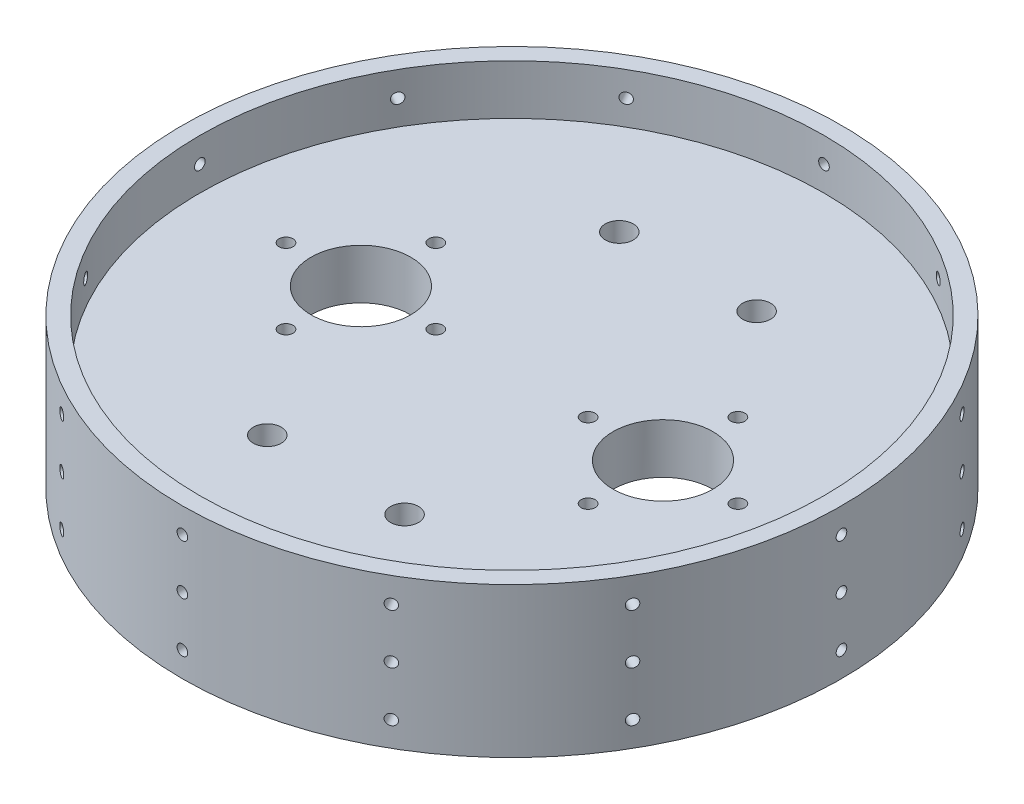
from build123d import *

# Parameters (mm, degrees)
SKETCH1_W           = 127.635
SKETCH1_H           = 127.635
MAIN_PLATE_DEPTH    = 12.7
SKETCH9_R           = 85.725
BOSS_EXTRUDE1_DEPTH = 12.7
SKETCH10_R          = 97.039626961
SKETCH10_R_2        = 83.82
CUT_EXTRUDE1_DEPTH  = 167.64
SKETCH18_R          = 83.82
SKETCH18_R_2        = 79.375
BOSS_EXTRUDE2_DEPTH = 19.05
SKETCH15_R          = 1.35255
CUT_EXTRUDE3_DEPTH  = 15.24
CIRPATTERN1_COUNT   = 12
SKETCH21_R          = 12.7
SKETCH21_R_2        = 1.778
CO2_MOUNTS_DEPTH    = 26.4000001
SKETCH22_R          = 3.556
CUT_EXTRUDE5_DEPTH  = 26.4000001


with BuildPart() as part:
    # Sketch1 → Main Plate (new body)
    with BuildSketch(Plane(origin=(0, 0, 0), x_dir=(1, 0, 0), z_dir=(0, 1, 0))):
        with Locations((63.8175, 63.8175)):
            Rectangle(SKETCH1_W, SKETCH1_H)
    extrude(amount=MAIN_PLATE_DEPTH)

    # Sketch9 → Boss-Extrude1 (add)
    with BuildSketch(Plane(origin=(0, 12.7, 0), x_dir=(1, 0, 0), z_dir=(0, 1, 0))):
        with Locations((63.8175, 63.8175)):
            Circle(SKETCH9_R)
    extrude(amount=-BOSS_EXTRUDE1_DEPTH)

    # Sketch10 → Cut-Extrude1 (cut)
    with BuildSketch(Plane(origin=(0, 12.7, 0), x_dir=(1, 0, 0), z_dir=(0, 1, 0))):
        with Locations((63.8175, 63.8175)):
            Circle(SKETCH10_R)
        with Locations((63.8175, 63.8175)):
            Circle(SKETCH10_R_2, mode=Mode.SUBTRACT)
    extrude(amount=-CUT_EXTRUDE1_DEPTH, mode=Mode.SUBTRACT)

    # Sketch18 → Boss-Extrude2 (add, symmetric)
    with BuildSketch(Plane(origin=(0, 6.35, 0), x_dir=(1, 0, 0), z_dir=(0, 1, 0))):
        with Locations((63.8175, 63.8175)):
            Circle(SKETCH18_R)
        with Locations((63.8175, 63.8175)):
            Circle(SKETCH18_R_2, mode=Mode.SUBTRACT)
    extrude(amount=BOSS_EXTRUDE2_DEPTH, both=True)

    # Sketch15 → Cut-Extrude3 (cut)
    with BuildSketch(Plane.ZY.offset(20.0025)):
        with Locations((-63.8175, 6.35)):
            Circle(SKETCH15_R)
        with Locations((-63.8175, 19.05)):
            Circle(SKETCH15_R)
        with Locations((-63.8175, -6.35)):
            Circle(SKETCH15_R)
    cut_extrude3 = extrude(amount=-CUT_EXTRUDE3_DEPTH, mode=Mode.SUBTRACT)

    # CirPattern1: Cut-Extrude3 ×12 about axis
    cirpattern1_axis = Axis((63.8175, 0, -63.8175), (0, 1, 0))
    for i in range(1, CIRPATTERN1_COUNT):
        add(cut_extrude3.rotate(cirpattern1_axis, i * 360 / CIRPATTERN1_COUNT), mode=Mode.SUBTRACT)

    # Sketch21 → CO2 Mounts (cut, through all)
    with BuildSketch(Plane(origin=(0, 12.7, 0), x_dir=(1, 0, 0), z_dir=(0, 1, 0))):
        with Locations((102.235, 63.8175)):
            Circle(SKETCH21_R)
        with Locations((102.235, 82.8675)):
            Circle(SKETCH21_R_2)
        with Locations((25.4, 63.8175)):
            Circle(SKETCH21_R)
        with Locations((121.285, 63.8175)):
            Circle(SKETCH21_R_2)
        with Locations((102.235, 44.7675)):
            Circle(SKETCH21_R_2)
        with Locations((83.185, 63.8175)):
            Circle(SKETCH21_R_2)
        with Locations((25.4, 82.8675)):
            Circle(SKETCH21_R_2)
        with Locations((6.35, 63.8175)):
            Circle(SKETCH21_R_2)
        with Locations((25.4, 44.7675)):
            Circle(SKETCH21_R_2)
        with Locations((44.45, 63.8175)):
            Circle(SKETCH21_R_2)
    extrude(amount=-CO2_MOUNTS_DEPTH, mode=Mode.SUBTRACT)

    # Sketch22 → Cut-Extrude5 (cut, through all)
    with BuildSketch(Plane(origin=(0, 12.7, 0), x_dir=(1, 0, 0), z_dir=(0, 1, 0))):
        with Locations((46.355, 108.585)):
            Circle(SKETCH22_R)
        with Locations((81.28, 108.585)):
            Circle(SKETCH22_R)
        with Locations((81.28, 19.05)):
            Circle(SKETCH22_R)
        with Locations((46.355, 19.05)):
            Circle(SKETCH22_R)
    extrude(amount=-CUT_EXTRUDE5_DEPTH, mode=Mode.SUBTRACT)


solid = part.part
